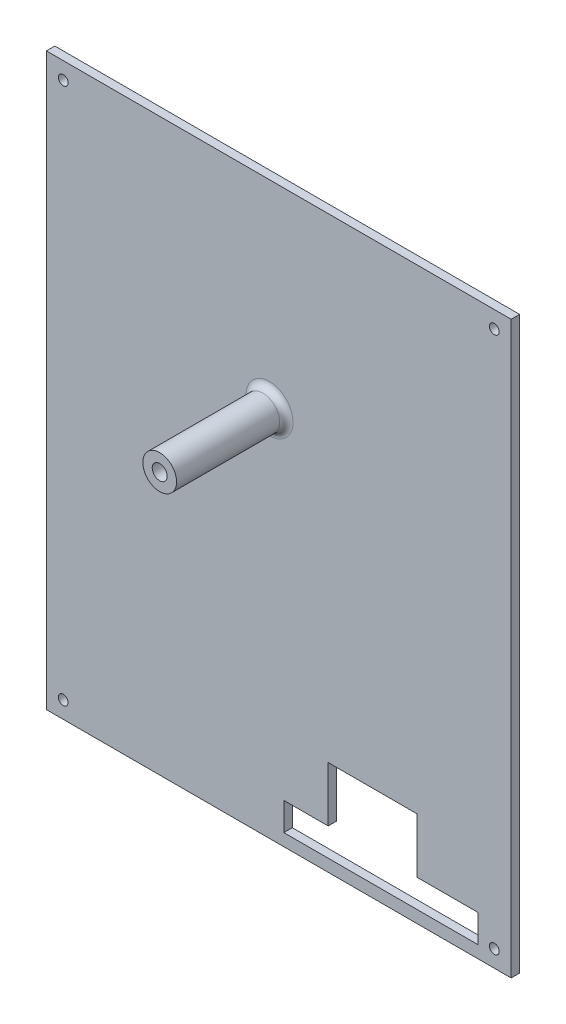
from build123d import *

# Parameters (mm, degrees)
SKETCH1_W           = 139.7
SKETCH1_H           = 171.45
BOSS_EXTRUDE1_DEPTH = 2.54
CUT_EXTRUDE1_DEPTH  = 2.54
SKETCH12_R          = 1.46685
CUT_EXTRUDE6_DEPTH  = 3.54
SKETCH24_R          = 5.075
BOSS_EXTRUDE8_DEPTH = 33
FILLET2_R           = 2
SKETCH26_R          = 2.25
CUT_EXTRUDE16_DEPTH = 5


with BuildPart() as part:
    # Sketch1 → Boss-Extrude1 (new body)
    with BuildSketch(Plane.XY):
        with Locations((-69.85, 85.725)):
            Rectangle(SKETCH1_W, SKETCH1_H)
    extrude(amount=BOSS_EXTRUDE1_DEPTH)

    # Sketch3 → Cut-Extrude1 (cut)
    with BuildSketch(Plane.XY.offset(2.54)):
        Polygon((-28.321, 12.065), (-9.906, 12.065), (-9.906, 3.683), (-68.326, 3.683), (-68.326, 12.065), (-54.991, 12.065), (-54.991, 28.575), (-49.911, 28.575), (-28.321, 28.575), align=None)
    extrude(amount=-CUT_EXTRUDE1_DEPTH, mode=Mode.SUBTRACT)

    # Sketch12 → Cut-Extrude6 (cut, through all)
    with BuildSketch(Plane.XY.offset(2.54)):
        with Locations((-134.62, 5.08)):
            Circle(SKETCH12_R)
        with Locations((-134.62, 166.37)):
            Circle(SKETCH12_R)
        with Locations((-5.08, 166.37)):
            Circle(SKETCH12_R)
        with Locations((-5.08, 5.08)):
            Circle(SKETCH12_R)
    extrude(amount=-CUT_EXTRUDE6_DEPTH, mode=Mode.SUBTRACT)

    # Sketch24 → Boss-Extrude8 (add)
    with BuildSketch(Plane.XY.offset(2.54)):
        with Locations((-72.633345717, 111.8489)):
            Circle(SKETCH24_R)
    extrude(amount=BOSS_EXTRUDE8_DEPTH)

    # Fillet2
    fillet2_edges = [part.edges().sort_by_distance(p)[0] for p in [
        (-77.708345717, 111.8489, 2.54),
    ]]
    fillet(fillet2_edges, radius=FILLET2_R)

    # Sketch26 → Cut-Extrude16 (cut)
    with BuildSketch(Plane.XY.offset(35.54)):
        with Locations((-72.633345717, 111.8489)):
            Circle(SKETCH26_R)
    extrude(amount=-CUT_EXTRUDE16_DEPTH, mode=Mode.SUBTRACT)


solid = part.part
